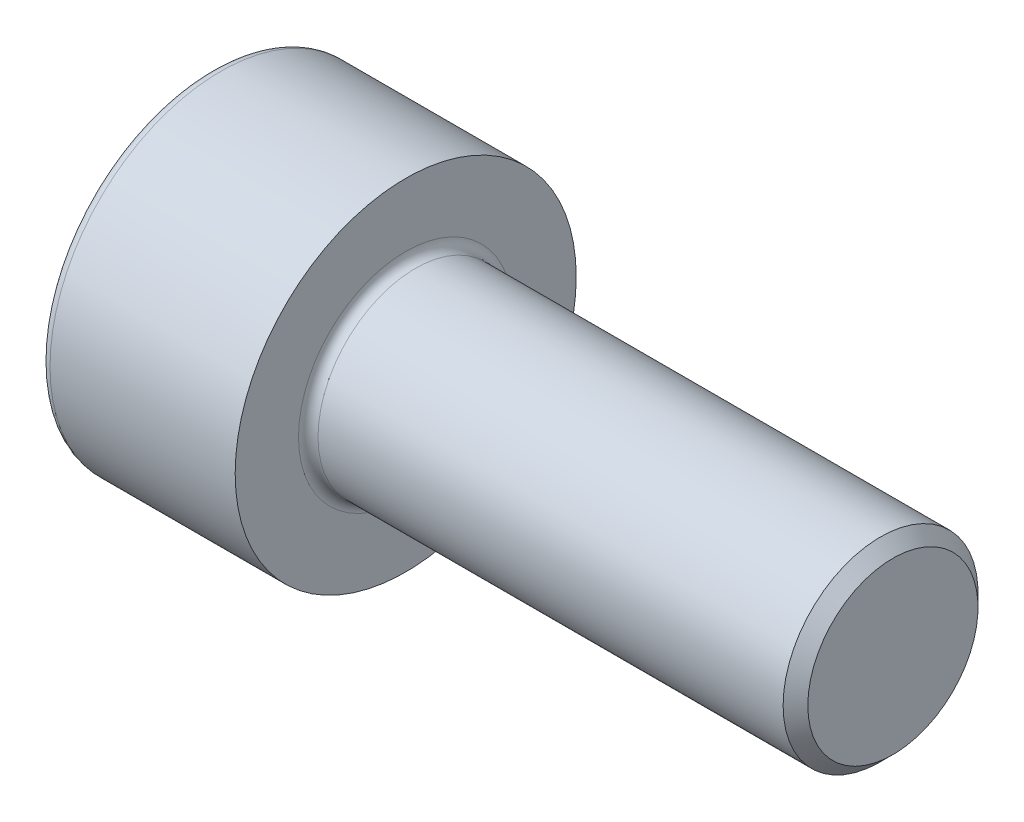
from build123d import *

# Parameters (mm, degrees)
CUT_EXTRUDE1_DEPTH = 2


with BuildPart() as part:
    # Sketch1 → Revolve1 (revolve)
    with BuildSketch(Plane.XY):
        with BuildLine():
            Line((9.7465, 2), (0.2, 2))
            ThreePointArc((0.2, 2), (0.058578644, 2.058578644), (0, 2.2))
            Line((0, 2.2), (0, 3.5))
            Line((0, 3.5), (-3.8, 3.5))
            ThreePointArc((-3.8, 3.5), (-3.941421356, 3.441421356), (-4, 3.3))
            Line((-4, 3.3), (-4, 0))
            Line((-4, 0), (10, 0))
            Line((10, 0), (10, 1.7465))
            Line((10, 1.7465), (9.7465, 2))
        make_face()
    revolve(axis=Axis((-4, 0, 0), (1, 0, 0)))

    # Sketch2 → Cut-Extrude1 (cut)
    with BuildSketch(Plane.ZY.offset(4)):
        Polygon((1.535, 0.886232663), (0, 1.772465326), (-1.535, 0.886232663), (-1.535, -0.886232663), (0, -1.772465326), (1.535, -0.886232663), align=None)
    extrude(amount=-CUT_EXTRUDE1_DEPTH, mode=Mode.SUBTRACT)


solid = part.part
